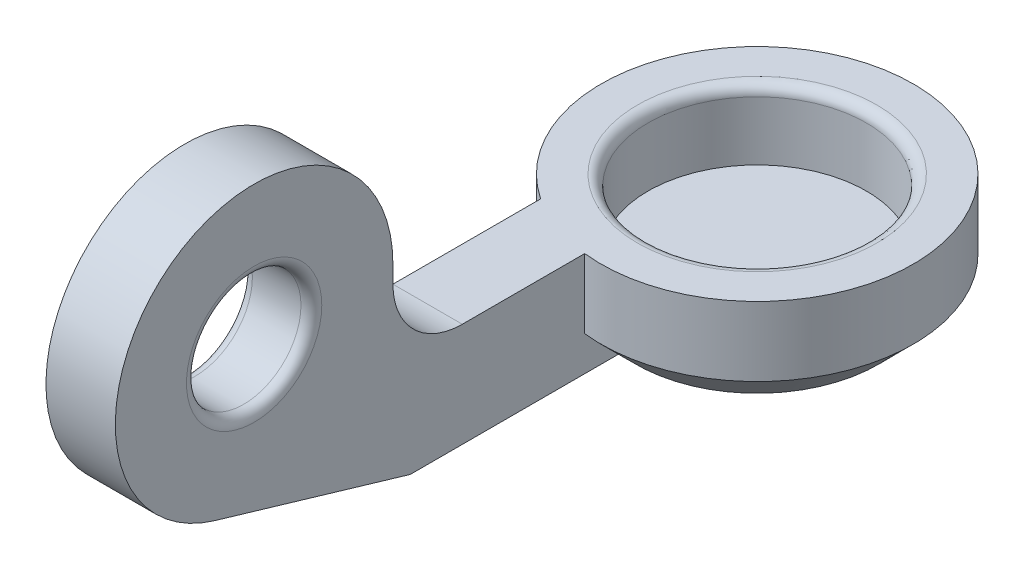
from build123d import *

# Parameters (mm, degrees)
SKETCH_6_R          = 4.5
EXTRUDE_4_DEPTH     = 3
SKETCH_7_R          = 3.15
CUT_EXTRUDE_4_DEPTH = 2
SKETCH_8_R          = 4
EXTRUDE_5_DEPTH     = 2
EXTRUDE_7_DEPTH     = 2
EXTRUDE_8_REACH     = 10
SKETCH_11_R         = 1.65
CUT_EXTRUDE_6_DEPTH = 2
CUT_EXTRUDE_7_REACH = 9
FILLET_4_R          = 2
FILLET_1_R          = 0.3
FILLET_2_R          = 0.3
FILLET_3_R          = 0.3


with BuildPart() as part:
    # 草图6 → 凸台-拉伸4 (new body)
    with BuildSketch(Plane(origin=(0, 0, 0), x_dir=(1, 0, 0), z_dir=(0, 1, 0))):
        Circle(SKETCH_6_R)
    extrude(amount=-EXTRUDE_4_DEPTH)

    # 草图7 → 切除-拉伸4 (cut)
    with BuildSketch(Plane(origin=(0, 0, 0), x_dir=(1, 0, 0), z_dir=(0, 1, 0))):
        Circle(SKETCH_7_R)
    extrude(amount=-CUT_EXTRUDE_4_DEPTH, mode=Mode.SUBTRACT)

    # 草图15 → 切除-旋转2 (revolve, cut)
    with BuildSketch(Plane(origin=(0, 0, 0), x_dir=(0, 0, -1), z_dir=(1, 0, 0))):
        Polygon((4.5, -3), (4.5, -2), (3.5, -3), align=None)
    revolve(axis=Axis((0, 0, 0), (0, -1, 0)), mode=Mode.SUBTRACT)



with BuildPart() as body_2:
    # 草图8 → 凸台-拉伸5 (new body)
    with BuildSketch(Plane(origin=(-0.5, 0, 0), x_dir=(0, 0, -1), z_dir=(1, 0, 0))):
        with Locations((-14, 2.5)):
            Circle(SKETCH_8_R)
    extrude(amount=-EXTRUDE_5_DEPTH)


with BuildPart() as part_1:
    add(part.part)

    add(body_2.part)  # 凸台-拉伸7 merges body 2
    # 草图9 → 凸台-拉伸7 (add)
    with BuildSketch(Plane(origin=(-0.5, 0, 0), x_dir=(0, 0, -1), z_dir=(1, 0, 0))):
        Polygon((-9.5, -3), (-15.133083988, -1.336159626), (-10.74928321, 0.169154585), (-10, 2.5), (-6.344746865, 2.002637663), (-3.5, 0), (-3.5, -3), (-3.52896076, -3), align=None)
    extrude(amount=-EXTRUDE_7_DEPTH)

    # 草图16 → 凸台-拉伸8 (add, up to next)
    with BuildSketch(Plane(origin=(0, 0, 3.5), x_dir=(-1, 0, 0), z_dir=(0, 0, -1)), mode=Mode.PRIVATE) as extrude_8_sk1:
        Polygon((2.5, -3), (2.5, -2.198837366), (0.5, -2.955716811), (0.5, -3), align=None)
    extrude_8_tool1 = extrude(extrude_8_sk1.sketch, amount=EXTRUDE_8_REACH, mode=Mode.PRIVATE) - part_1.part
    add(extrude_8_tool1.solids().sort_by_distance((-1.798414, -2.732173, 3.5))[0])

    # 草图11 → 切除-拉伸6 (cut)
    with BuildSketch(Plane(origin=(-0.5, 0, 0), x_dir=(0, 0, -1), z_dir=(1, 0, 0))):
        with Locations((-14, 2.5)):
            Circle(SKETCH_11_R)
    extrude(amount=-CUT_EXTRUDE_6_DEPTH, mode=Mode.SUBTRACT)

    # 草图12 → 切除-拉伸7 (cut, up to next)
    with BuildSketch(Plane.ZY.offset(2.5), mode=Mode.PRIVATE) as cut_extrude_7_sk1:
        Polygon((3.5, 0), (3.741657387, 0), (10, 0), (10, 2.5), (6.344746865, 2.002637663), align=None)
    cut_extrude_7_tool1 = extrude(cut_extrude_7_sk1.sketch, amount=-CUT_EXTRUDE_7_REACH, mode=Mode.PRIVATE) & part_1.part
    add(cut_extrude_7_tool1.solids().sort_by_distance((-2.5, 1.011261, 7.508576))[0], mode=Mode.SUBTRACT)

    # 圆角4
    fillet_4_edges = [part_1.edges().sort_by_distance(p)[0] for p in [
        (-1.5, 0, 10),
    ]]
    fillet(fillet_4_edges, radius=FILLET_4_R)

    # 圆角1
    fillet_1_edges = [part_1.edges().sort_by_distance(p)[0] for p in [
        (-3.15, 0, 0),
    ]]
    fillet(fillet_1_edges, radius=FILLET_1_R)

    # 圆角2
    fillet_2_edges = [part_1.edges().sort_by_distance(p)[0] for p in [
        (-0.5, 2.5, 15.65),
    ]]
    fillet(fillet_2_edges, radius=FILLET_2_R)

    # 圆角3
    fillet_3_edges = [part_1.edges().sort_by_distance(p)[0] for p in [
        (-2.5, 2.5, 15.65),
    ]]
    fillet(fillet_3_edges, radius=FILLET_3_R)


solid = part_1.part
